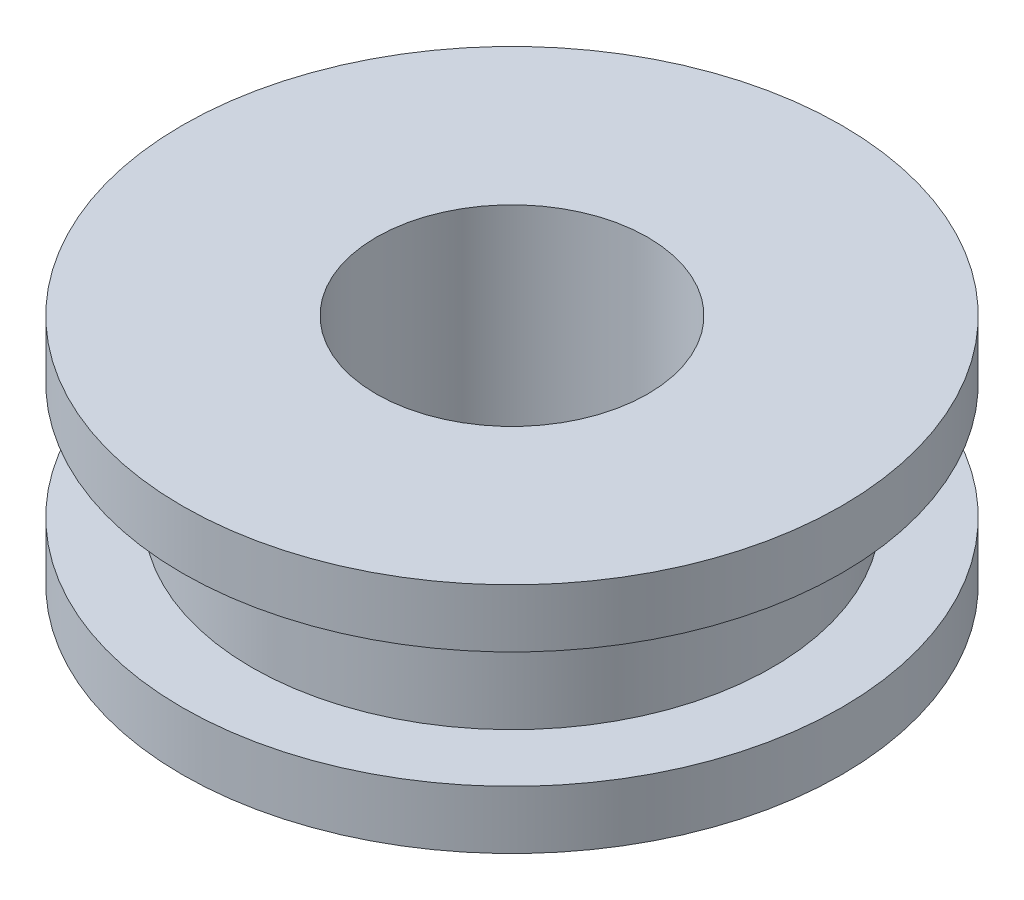
from build123d import *

# Parameters (mm, degrees)
SKIZZE1_R                       = 8.5
SKIZZE1_R_2                     = 3.5
AUFSATZ_LINEAR_AUSTRAGEN1_DEPTH = 6
SCHNITT_LINEAR_START            = 1.5
SKIZZE2_R                       = 13.890066822
SKIZZE2_R_2                     = 6.709730291
SCHNITT_LINEAR_AUSTRAGEN1_DEPTH = 3


with BuildPart() as part:
    # Skizze1 → Aufsatz-Linear austragen1 (new body)
    with BuildSketch(Plane(origin=(0, 0, 0), x_dir=(1, 0, 0), z_dir=(0, 1, 0))):
        Circle(SKIZZE1_R)
        Circle(SKIZZE1_R_2, mode=Mode.SUBTRACT)
    extrude(amount=AUFSATZ_LINEAR_AUSTRAGEN1_DEPTH)

    # Skizze2 → Schnitt-Linear austragen1 (cut)
    with BuildSketch(Plane(origin=(0, 0, 0), x_dir=(1, 0, 0), z_dir=(0, 1, 0)).offset(SCHNITT_LINEAR_START)):
        Circle(SKIZZE2_R)
        Circle(SKIZZE2_R_2, mode=Mode.SUBTRACT)
    extrude(amount=SCHNITT_LINEAR_AUSTRAGEN1_DEPTH, mode=Mode.SUBTRACT)


solid = part.part
